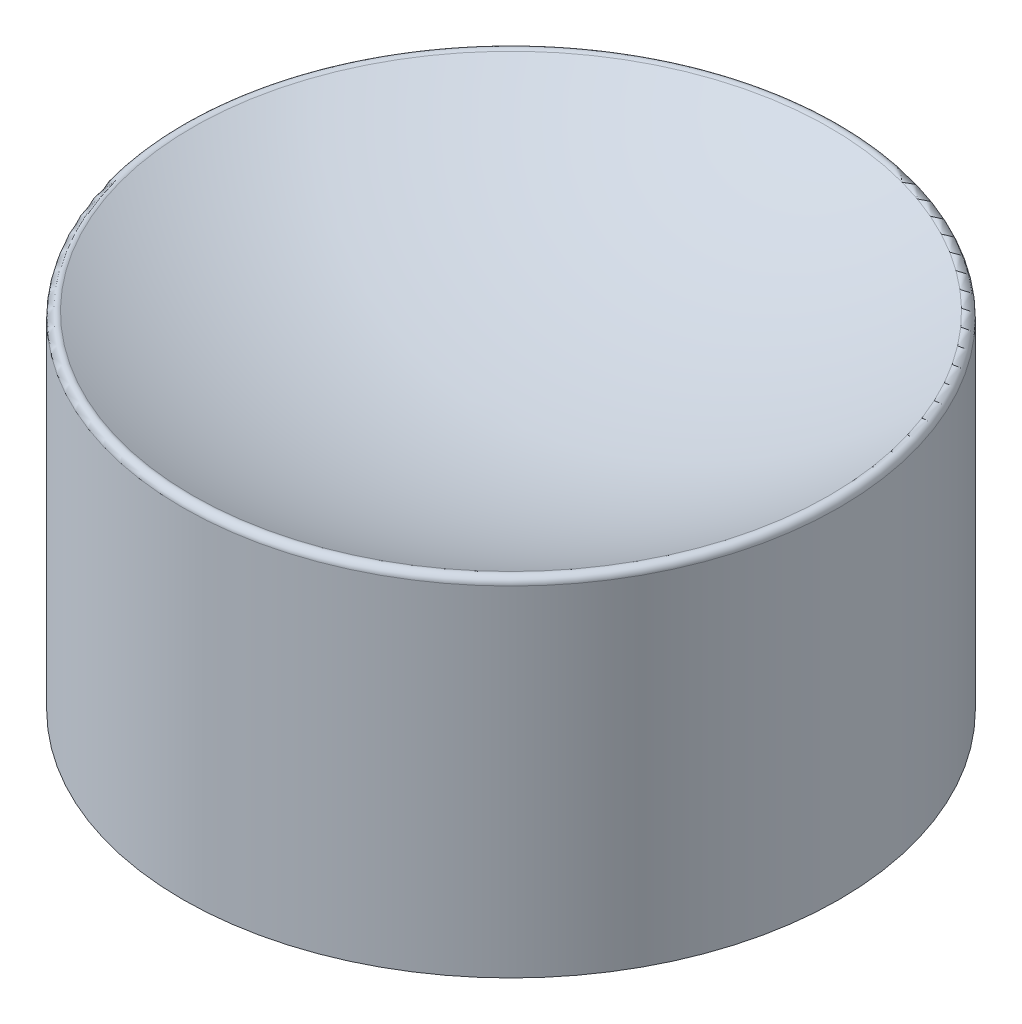
from build123d import *

# Parameters (mm, degrees)
SKETCH2_R           = 5
BOSS_EXTRUDE1_DEPTH = 8
FILLET1_R           = 0.1


with BuildPart() as part:
    # Sketch2 → Boss-Extrude1 (new body)
    with BuildSketch(Plane(origin=(0, 0, 0), x_dir=(1, 0, 0), z_dir=(0, 1, 0))):
        Circle(SKETCH2_R)
    extrude(amount=BOSS_EXTRUDE1_DEPTH)

    # Sketch3 one side → Cut-Revolve1 (revolve, cut)
    with BuildSketch(Plane.XY):
        with BuildLine():
            ThreePointArc((0, 4), (7.071067812, 6.928932188), (10, 14))
            ThreePointArc((10, 14), (7.071067812, 21.071067812), (0, 24))
            Line((0, 24), (0, 4))
        make_face()
    revolve(axis=Axis((0, 24, 0), (0, -1, 0)), mode=Mode.SUBTRACT)

    # Fillet1
    fillet1_edges = [part.edges().sort_by_distance(p)[0] for p in [
        (-5, 5.339745962, 0),
    ]]
    fillet(fillet1_edges, radius=FILLET1_R)


solid = part.part
